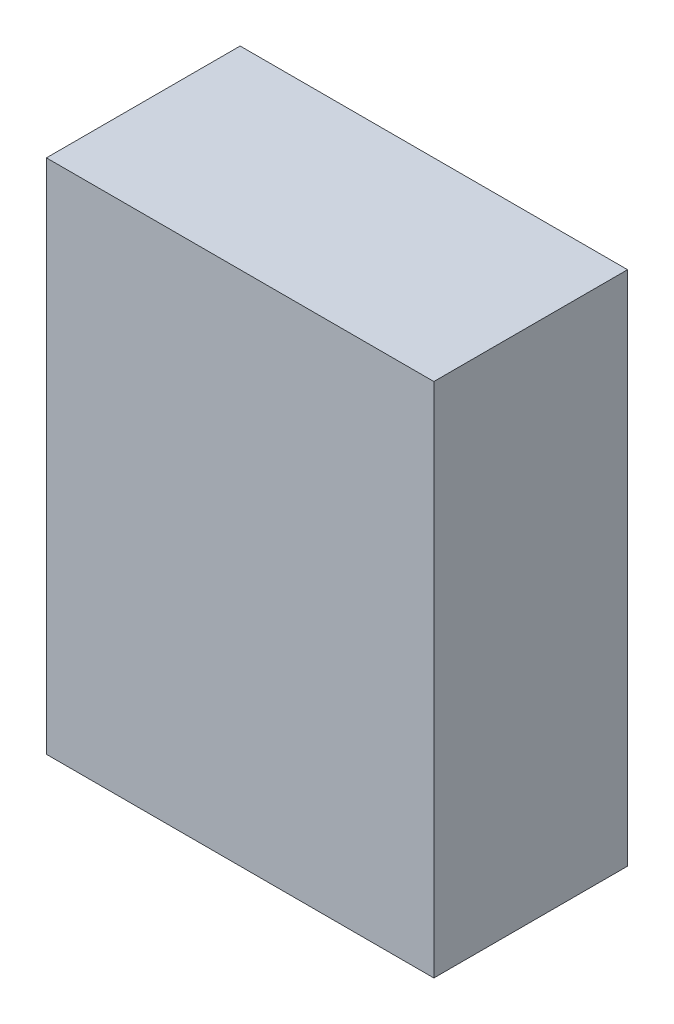
from build123d import *

# Parameters (mm, degrees)
SKETCH_1_W      = 1500
SKETCH_1_H      = 750
EXTRUDE_1_DEPTH = 2000


with BuildPart() as part:
    # 草圖1 → 填料-伸長1 (new body)
    with BuildSketch(Plane(origin=(0, 0, 0), x_dir=(1, 0, 0), z_dir=(0, 1, 0))):
        Rectangle(SKETCH_1_W, SKETCH_1_H)
    extrude(amount=EXTRUDE_1_DEPTH)


solid = part.part
